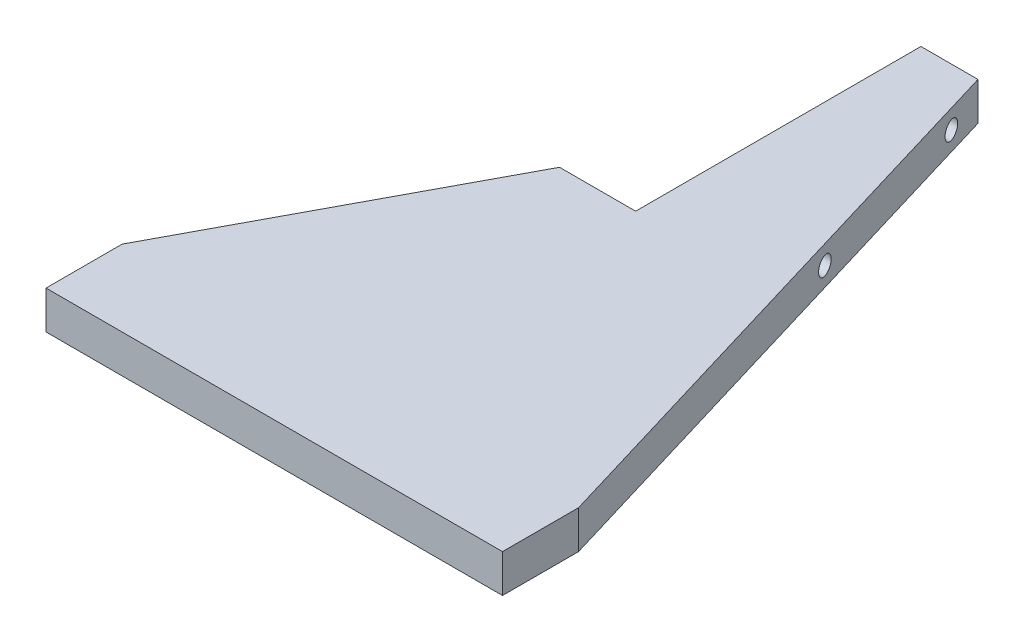
from build123d import *

# Parameters (mm, degrees)
BOSS_EXTRUDE1_DEPTH     = 6.35
SKETCH2_R               = 1.5
CUT_EXTRUDE1_DEPTH      = 39.1
CUT_EXTRUDE1_DEPTH_BACK = 39.1


with BuildPart() as part:
    # Sketch1 → Boss-Extrude1 (new body)
    with BuildSketch(Plane(origin=(0, 0, 0), x_dir=(1, 0, 0), z_dir=(0, 1, 0))):
        Polygon((0, 0), (0, 12.7), (25.4, 60.325), (38.1, 60.325), (38.1, 107.95), (47.625, 107.95), (76.2, 12.7), (76.2, 0), align=None)
    extrude(amount=BOSS_EXTRUDE1_DEPTH)

    # Sketch2 → Cut-Extrude1 (cut, two sides)
    with BuildSketch(Plane.ZY.offset(-38.1)) as cut_extrude1_sk:
        with Locations((-101.6, 3.175)):
            Circle(SKETCH2_R)
        with Locations((-71.4375, 3.175)):
            Circle(SKETCH2_R)
    extrude(amount=CUT_EXTRUDE1_DEPTH, mode=Mode.SUBTRACT)
    extrude(cut_extrude1_sk.sketch, amount=-CUT_EXTRUDE1_DEPTH_BACK, mode=Mode.SUBTRACT)


solid = part.part
